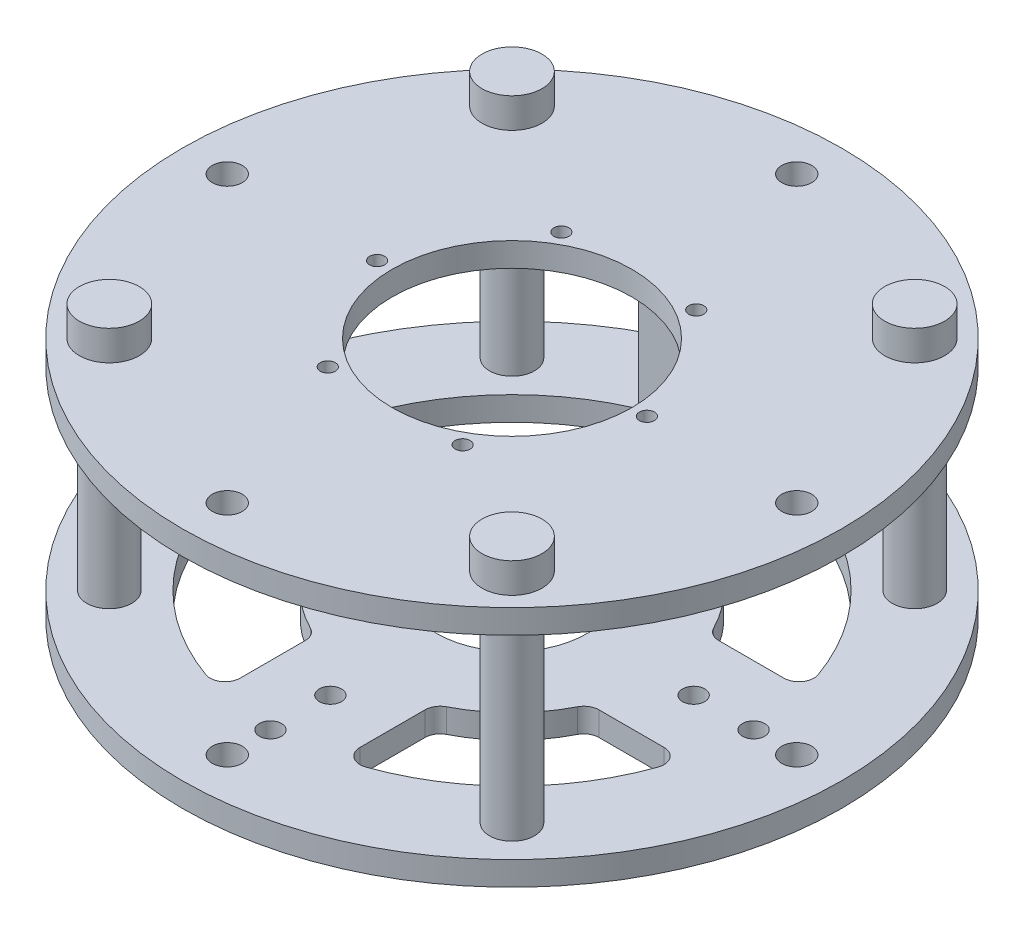
from build123d import *

# Parameters (mm, degrees)
SKETCH1_R           = 139.7
SKETCH1_R_2         = 31.75
SKETCH1_R_3         = 6.35
SKETCH1_R_4         = 4.699
BOSS_EXTRUDE1_DEPTH = 10.16
SKETCH2_R           = 9.525
BOSS_EXTRUDE2_DEPTH = 82.296
SKETCH3_R           = 139.7
SKETCH3_R_2         = 50.8
SKETCH3_R_3         = 6.35
SKETCH3_R_4         = 3.175
BOSS_EXTRUDE3_DEPTH = 10.16
SKETCH4_R           = 12.7
BOSS_EXTRUDE4_DEPTH = 12.7
SKETCH6_W           = 19.812
SKETCH6_H           = 50.8
BOSS_EXTRUDE5_DEPTH = 76.2


with BuildPart() as part:
    # Sketch1 → Boss-Extrude1 (new body)
    with BuildSketch(Plane(origin=(0, 0, 0), x_dir=(1, 0, 0), z_dir=(0, 1, 0))):
        Circle(SKETCH1_R)
        Circle(SKETCH1_R_2, mode=Mode.SUBTRACT)
        with Locations((0, 120.65)):
            Circle(SKETCH1_R_3, mode=Mode.SUBTRACT)
        with Locations((0, 102.362)):
            Circle(SKETCH1_R_4, mode=Mode.SUBTRACT)
        with Locations((0, 76.962)):
            Circle(SKETCH1_R_4, mode=Mode.SUBTRACT)
        with Locations((85.31243315, 85.31243315)):
            Circle(SKETCH1_R_3, mode=Mode.SUBTRACT)
        with Locations((120.65, 0)):
            Circle(SKETCH1_R_3, mode=Mode.SUBTRACT)
        with Locations((85.31243315, -85.31243315)):
            Circle(SKETCH1_R_3, mode=Mode.SUBTRACT)
        with Locations((0, -120.65)):
            Circle(SKETCH1_R_3, mode=Mode.SUBTRACT)
        with Locations((-85.31243315, -85.31243315)):
            Circle(SKETCH1_R_3, mode=Mode.SUBTRACT)
        with Locations((-120.65, 0)):
            Circle(SKETCH1_R_3, mode=Mode.SUBTRACT)
        with Locations((-85.31243315, 85.31243315)):
            Circle(SKETCH1_R_3, mode=Mode.SUBTRACT)
        with Locations((102.362, 0)):
            Circle(SKETCH1_R_4, mode=Mode.SUBTRACT)
        with Locations((76.962, 0)):
            Circle(SKETCH1_R_4, mode=Mode.SUBTRACT)
        with Locations((0, -102.362)):
            Circle(SKETCH1_R_4, mode=Mode.SUBTRACT)
        with Locations((0, -76.962)):
            Circle(SKETCH1_R_4, mode=Mode.SUBTRACT)
        with Locations((-102.362, 0)):
            Circle(SKETCH1_R_4, mode=Mode.SUBTRACT)
        with Locations((-76.962, 0)):
            Circle(SKETCH1_R_4, mode=Mode.SUBTRACT)
        with BuildLine():
            Line((-25.4, 89.802561211), (-25.4, 62.217039467))
            ThreePointArc((-25.4, 62.217039467), (-26.334701805, 58.900860121), (-28.863636364, 56.56094497))
            ThreePointArc((-28.863636364, 56.56094497), (-44.901280605, 44.901280605), (-56.56094497, 28.863636364))
            ThreePointArc((-56.56094497, 28.863636364), (-58.900860121, 26.334701805), (-62.217039467, 25.4))
            Line((-62.217039467, 25.4), (-89.802561211, 25.4))
            ThreePointArc((-89.802561211, 25.4), (-94.9873145, 28.083825791), (-95.789398625, 33.866666667))
            ThreePointArc((-95.789398625, 33.866666667), (-71.842048969, 71.842048969), (-33.866666667, 95.789398625))
            ThreePointArc((-33.866666667, 95.789398625), (-28.083825791, 94.9873145), (-25.4, 89.802561211))
        make_face(mode=Mode.SUBTRACT)
        with BuildLine():
            Line((25.4, 89.802561211), (25.4, 62.217039467))
            ThreePointArc((25.4, 62.217039467), (26.334701805, 58.900860121), (28.863636364, 56.56094497))
            ThreePointArc((28.863636364, 56.56094497), (44.901280605, 44.901280605), (56.56094497, 28.863636364))
            ThreePointArc((56.56094497, 28.863636364), (58.900860121, 26.334701805), (62.217039467, 25.4))
            Line((62.217039467, 25.4), (89.802561211, 25.4))
            ThreePointArc((89.802561211, 25.4), (94.9873145, 28.083825791), (95.789398625, 33.866666667))
            ThreePointArc((95.789398625, 33.866666667), (71.842048969, 71.842048969), (33.866666667, 95.789398625))
            ThreePointArc((33.866666667, 95.789398625), (28.083825791, 94.9873145), (25.4, 89.802561211))
        make_face(mode=Mode.SUBTRACT)
        with BuildLine():
            Line((89.802561211, -25.4), (62.217039467, -25.4))
            ThreePointArc((62.217039467, -25.4), (58.900860121, -26.334701805), (56.56094497, -28.863636364))
            ThreePointArc((56.56094497, -28.863636364), (44.901280605, -44.901280605), (28.863636364, -56.56094497))
            ThreePointArc((28.863636364, -56.56094497), (26.334701805, -58.900860121), (25.4, -62.217039467))
            Line((25.4, -62.217039467), (25.4, -89.802561211))
            ThreePointArc((25.4, -89.802561211), (28.083825791, -94.9873145), (33.866666667, -95.789398625))
            ThreePointArc((33.866666667, -95.789398625), (71.842048969, -71.842048969), (95.789398625, -33.866666667))
            ThreePointArc((95.789398625, -33.866666667), (94.9873145, -28.083825791), (89.802561211, -25.4))
        make_face(mode=Mode.SUBTRACT)
        with BuildLine():
            Line((-25.4, -89.802561211), (-25.4, -62.217039467))
            ThreePointArc((-25.4, -62.217039467), (-26.334701805, -58.900860121), (-28.863636364, -56.56094497))
            ThreePointArc((-28.863636364, -56.56094497), (-44.901280605, -44.901280605), (-56.56094497, -28.863636364))
            ThreePointArc((-56.56094497, -28.863636364), (-58.900860121, -26.334701805), (-62.217039467, -25.4))
            Line((-62.217039467, -25.4), (-89.802561211, -25.4))
            ThreePointArc((-89.802561211, -25.4), (-94.9873145, -28.083825791), (-95.789398625, -33.866666667))
            ThreePointArc((-95.789398625, -33.866666667), (-71.842048969, -71.842048969), (-33.866666667, -95.789398625))
            ThreePointArc((-33.866666667, -95.789398625), (-28.083825791, -94.9873145), (-25.4, -89.802561211))
        make_face(mode=Mode.SUBTRACT)
    extrude(amount=BOSS_EXTRUDE1_DEPTH)

    # Sketch2 → Boss-Extrude2 (add)
    with BuildSketch(Plane(origin=(0, 10.16, 0), x_dir=(1, 0, 0), z_dir=(0, 1, 0))):
        with Locations((-85.31243315, 85.31243315)):
            Circle(SKETCH2_R)
        with Locations((85.31243315, 85.31243315)):
            Circle(SKETCH2_R)
        with Locations((85.31243315, -85.31243315)):
            Circle(SKETCH2_R)
        with Locations((-85.31243315, -85.31243315)):
            Circle(SKETCH2_R)
    extrude(amount=BOSS_EXTRUDE2_DEPTH)

    # Sketch3 → Boss-Extrude3 (add)
    with BuildSketch(Plane(origin=(0, 92.456, 0), x_dir=(1, 0, 0), z_dir=(0, 1, 0))):
        Circle(SKETCH3_R)
        Circle(SKETCH3_R_2, mode=Mode.SUBTRACT)
        with Locations((0, 120.65)):
            Circle(SKETCH3_R_3, mode=Mode.SUBTRACT)
        with Locations((85.31243315, 85.31243315)):
            Circle(SKETCH3_R_3, mode=Mode.SUBTRACT)
        with Locations((120.65, 0)):
            Circle(SKETCH3_R_3, mode=Mode.SUBTRACT)
        with Locations((85.31243315, -85.31243315)):
            Circle(SKETCH3_R_3, mode=Mode.SUBTRACT)
        with Locations((0, -120.65)):
            Circle(SKETCH3_R_3, mode=Mode.SUBTRACT)
        with Locations((-85.31243315, -85.31243315)):
            Circle(SKETCH3_R_3, mode=Mode.SUBTRACT)
        with Locations((-120.65, 0)):
            Circle(SKETCH3_R_3, mode=Mode.SUBTRACT)
        with Locations((-85.31243315, 85.31243315)):
            Circle(SKETCH3_R_3, mode=Mode.SUBTRACT)
        with Locations((-57.15, 0)):
            Circle(SKETCH3_R_4, mode=Mode.SUBTRACT)
        with Locations((-28.575, 49.493351826)):
            Circle(SKETCH3_R_4, mode=Mode.SUBTRACT)
        with Locations((28.575, 49.493351826)):
            Circle(SKETCH3_R_4, mode=Mode.SUBTRACT)
        with Locations((57.15, 0)):
            Circle(SKETCH3_R_4, mode=Mode.SUBTRACT)
        with Locations((28.575, -49.493351826)):
            Circle(SKETCH3_R_4, mode=Mode.SUBTRACT)
        with Locations((-28.575, -49.493351826)):
            Circle(SKETCH3_R_4, mode=Mode.SUBTRACT)
    extrude(amount=BOSS_EXTRUDE3_DEPTH)

    # Sketch4 → Boss-Extrude4 (add)
    with BuildSketch(Plane(origin=(0, 102.616, 0), x_dir=(1, 0, 0), z_dir=(0, 1, 0))):
        with Locations((-85.31243315, 85.31243315)):
            Circle(SKETCH4_R)
        with Locations((85.31243315, 85.31243315)):
            Circle(SKETCH4_R)
        with Locations((85.31243315, -85.31243315)):
            Circle(SKETCH4_R)
        with Locations((-85.31243315, -85.31243315)):
            Circle(SKETCH4_R)
    extrude(amount=BOSS_EXTRUDE4_DEPTH)

    # Sketch6 → Boss-Extrude5 (add)
    with BuildSketch(Plane(origin=(0, 10.16, 0), x_dir=(1, 0, 0), z_dir=(0, 1, 0))):
        with Locations((0, 88.9)):
            Rectangle(SKETCH6_W, SKETCH6_H)
    extrude(amount=BOSS_EXTRUDE5_DEPTH)


solid = part.part
